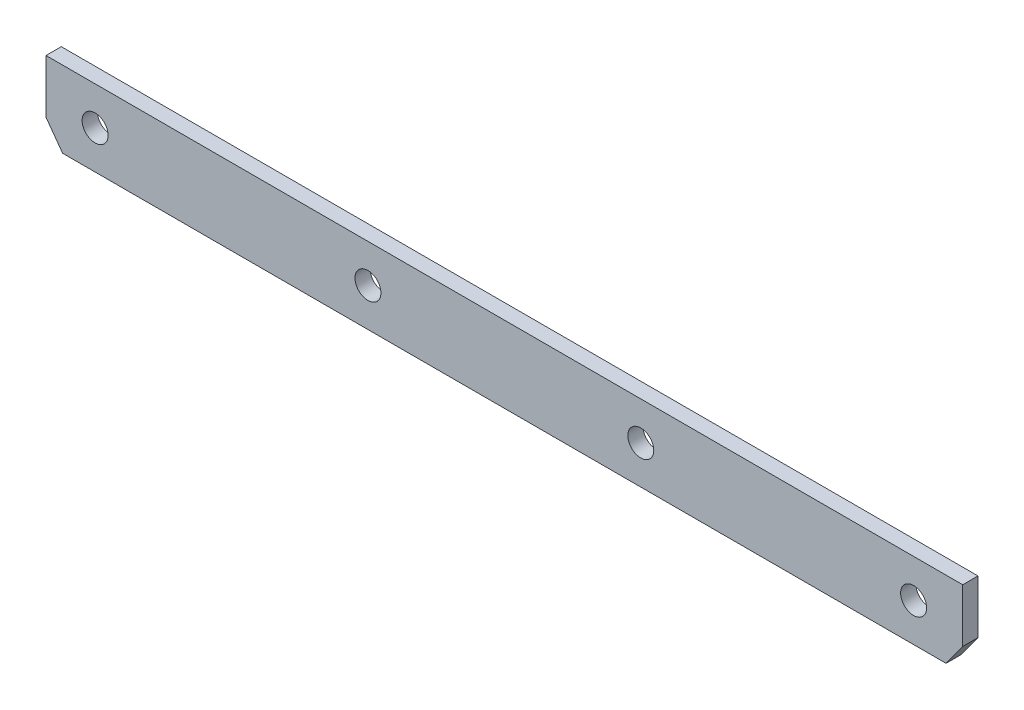
from build123d import *

# Parameters (mm, degrees)
SKETCH1_W               = 270
SKETCH1_H               = 10
BOSS_EXTRUDE1_DEPTH     = 2
CHAMFER1_SIZE           = 2
M3_CLEARANCE_HOLE1_D    = 3.4
LPATTERN1_COUNT         = 8
LPATTERN1_PITCH         = 35.714285714
CUT_EXTRUDE_THIN1_DEPTH = 10


with BuildPart() as part:
    # Sketch1 → Boss-Extrude1 (new body)
    with BuildSketch(Plane.XY):
        Rectangle(SKETCH1_W, SKETCH1_H)
    extrude(amount=BOSS_EXTRUDE1_DEPTH)

    # Chamfer1
    chamfer1_edges = [part.edges().sort_by_distance(p)[0] for p in [
        (135, -5, 1),
        (-135, -5, 1),
    ]]
    chamfer(chamfer1_edges, length=CHAMFER1_SIZE)

    # M3 Clearance Hole1 (through all)
    with Locations(Plane.XY.offset(2)):
        with Locations((125, 0)):
            m3_clearance_hole1 = Hole(M3_CLEARANCE_HOLE1_D / 2)

    # LPattern1: M3 Clearance Hole1 ×8
    with Locations(*[(-i * LPATTERN1_PITCH, 0, 0) for i in range(1, LPATTERN1_COUNT)]):
        add(m3_clearance_hole1, mode=Mode.SUBTRACT)

    # Sketch4 → Cut-Extrude-Thin1 (cut)
    with BuildSketch(Plane(origin=(0, 0, 0), x_dir=(-1, 0, 0), z_dir=(0, 0, -1))):
        Polygon((160, 105), (-160, 105), (-160, -34.491969623), (-108.772917365, -105), (108.772917365, -105), (160, -34.491969623), align=None)
        Polygon((60, 5), (-60, 5), (-60, -2), (-57.820372416, -5), (57.820372416, -5), (60, -2), align=None, mode=Mode.SUBTRACT)
    extrude(amount=-CUT_EXTRUDE_THIN1_DEPTH, mode=Mode.SUBTRACT)


solid = part.part
